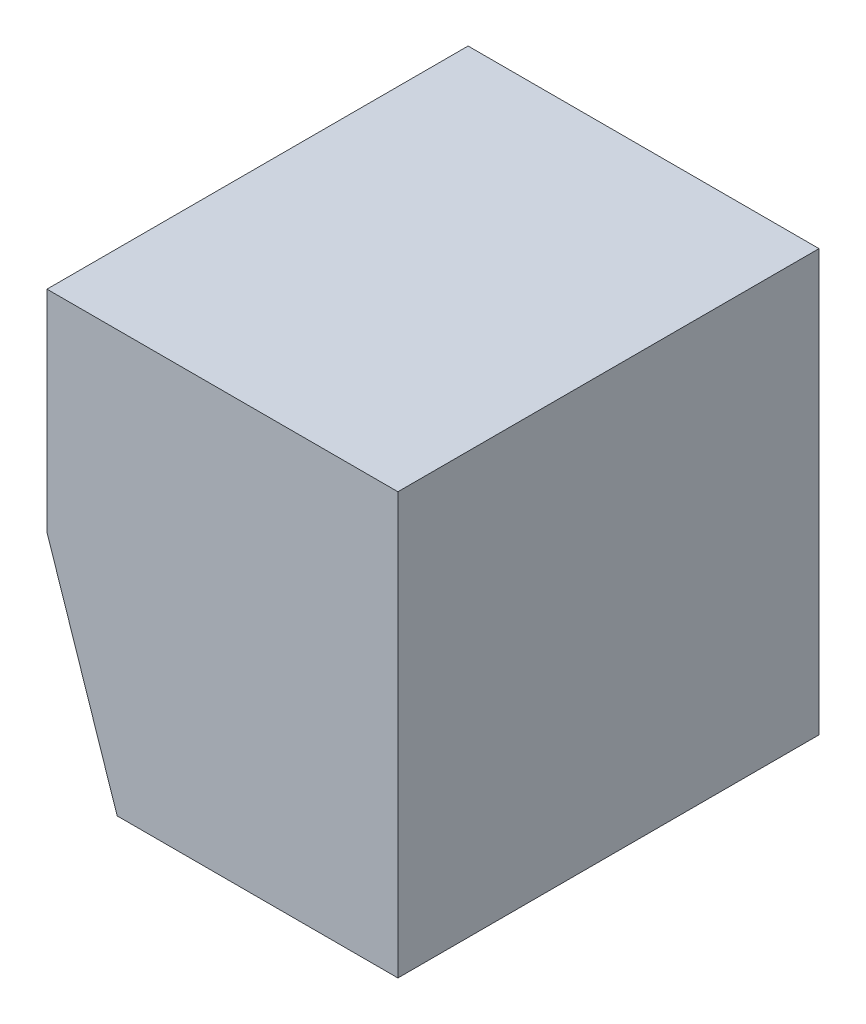
from build123d import *

# Parameters (mm, degrees)
EXTRUDE_1_DEPTH = 30


with BuildPart() as part:
    # Эскиз1 → Бобышка-Вытянуть1 (new body)
    with BuildSketch(Plane.XY):
        Polygon((0, 0), (0, -15), (5, -30), (25, -30), (25, 0), align=None)
    extrude(amount=EXTRUDE_1_DEPTH)


solid = part.part
